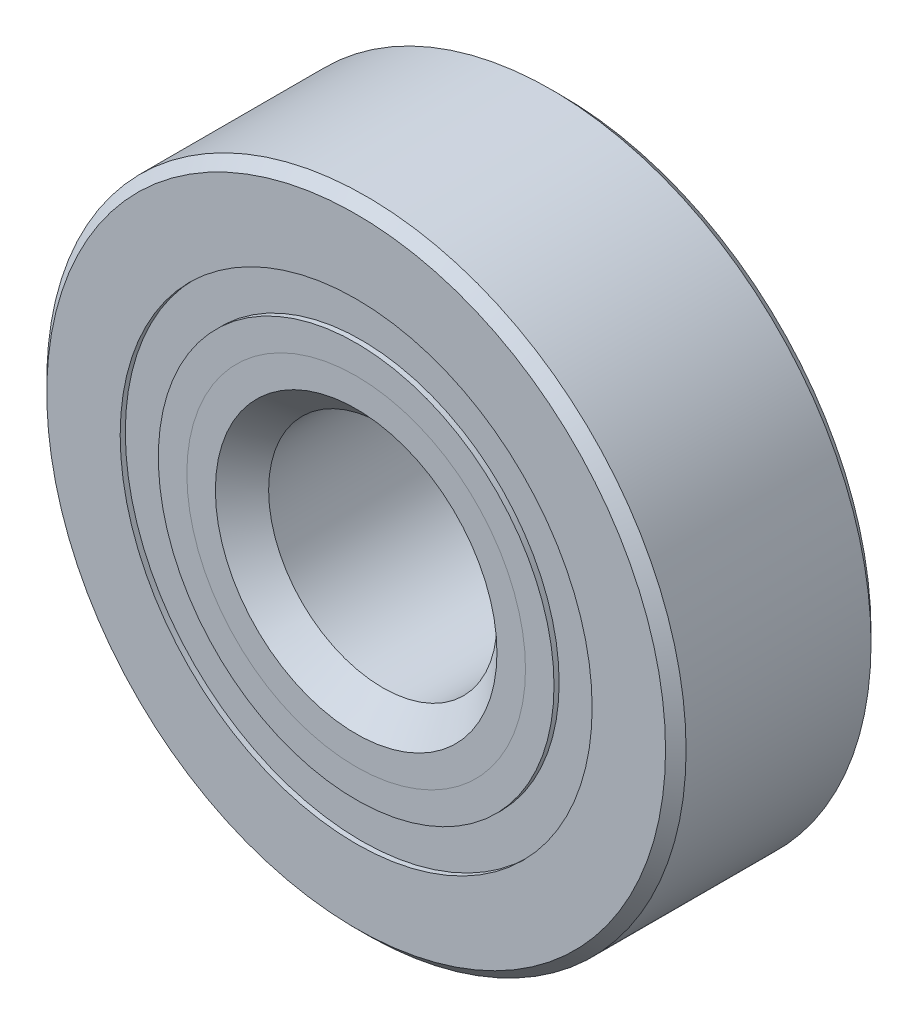
from build123d import *

# Parameters (mm, degrees)
CIRPATTERN1_COUNT = 8
SKETCH5_W         = 1.672929924
SKETCH5_H         = 1.325824176


with BuildPart() as part:
    # Sketch1 → Revolve1 (revolve)
    with BuildSketch(Plane(origin=(0, 0, 0), x_dir=(0, 0, -1), z_dir=(1, 0, 0))):
        with BuildLine():
            Line((3.2146875, 11.1125), (-3.2146875, 11.1125))
            Line((-3.2146875, 11.1125), (-3.571875, 10.7553125))
            Line((-3.571875, 10.7553125), (-3.571875, 8.203537088))
            Line((-3.571875, 8.203537088), (-1.5875, 8.203537088))
            ThreePointArc((-1.5875, 8.203537088), (0, 9.260976326), (1.5875, 8.203537088))
            Line((1.5875, 8.203537088), (3.571875, 8.203537088))
            Line((3.571875, 8.203537088), (3.571875, 10.7553125))
            Line((3.571875, 10.7553125), (3.2146875, 11.1125))
        make_face()
    revolve(axis=Axis((0, 0, 3.571875), (0, 0, -1)))


with BuildPart() as body_2:
    # Sketch2 → Revolve2 (revolve)
    with BuildSketch(Plane(origin=(0, 0, 0), x_dir=(0, 0, -1), z_dir=(1, 0, 0))):
        with BuildLine():
            Line((-3.571875, 6.877712912), (-1.5875, 6.877712912))
            ThreePointArc((-1.5875, 6.877712912), (-0.95372087, 6.108834098), (0, 5.820273674))
            Line((0, 5.820273674), (0, 4.894511837))
            Line((0, 4.894511837), (-2.580274462, 4.894511837))
            Line((-2.580274462, 4.894511837), (-3.571875, 5.886112374))
            Line((-3.571875, 5.886112374), (-3.571875, 6.877712912))
        make_face()
    revolve(axis=Axis((0, 0, 3.571875), (0, 0, -1)))


with BuildPart() as body_3:
    # Sketch3 → Revolve3 (revolve)
    with BuildSketch(Plane(origin=(0, 0, 0), x_dir=(0, 0, -1), z_dir=(1, 0, 0))):
        with BuildLine():
            Line((-3.571875, 5.886112374), (-2.580274462, 4.894511837))
            Line((-2.580274462, 4.894511837), (0, 4.894511837))
            Line((0, 4.894511837), (0, 5.820273674))
            ThreePointArc((0, 5.820273674), (0.95372087, 6.108834098), (1.5875, 6.877712912))
            Line((1.5875, 6.877712912), (3.571875, 6.877712912))
            Line((3.571875, 6.877712912), (3.571875, 4.3259375))
            Line((3.571875, 4.3259375), (3.2146875, 3.96875))
            Line((3.2146875, 3.96875), (-2.646113163, 3.96875))
            Line((-2.646113163, 3.96875), (-3.571875, 4.894511837))
            Line((-3.571875, 4.894511837), (-3.571875, 5.886112374))
        make_face()
    revolve(axis=Axis((0, 0, 3.571875), (0, 0, -1)))


with BuildPart() as body_4:
    # Sketch4 → Revolve4 (revolve)
    with BuildSketch(Plane(origin=(0, 0, 0), x_dir=(0, 0, -1), z_dir=(1, 0, 0))):
        with BuildLine():
            Line((-1.720351326, 7.540625), (1.720351326, 7.540625))
            ThreePointArc((1.720351326, 7.540625), (0, 9.260976326), (-1.720351326, 7.540625))
        make_face()
    revolve(axis=Axis((0, 7.540625, 1.720351326), (0, 0, -1)))


with BuildPart() as cirpattern1_1:
    # CirPattern1: pattern copy
    add(body_4.part.rotate(Axis((0, 0, -3.571875), (0, 0, 1)), 1 * 360 / CIRPATTERN1_COUNT))


with BuildPart() as cirpattern1_2:
    # CirPattern1: pattern copy
    add(body_4.part.rotate(Axis((0, 0, -3.571875), (0, 0, 1)), 2 * 360 / CIRPATTERN1_COUNT))


with BuildPart() as cirpattern1_3:
    # CirPattern1: pattern copy
    add(body_4.part.rotate(Axis((0, 0, -3.571875), (0, 0, 1)), 3 * 360 / CIRPATTERN1_COUNT))


with BuildPart() as cirpattern1_4:
    # CirPattern1: pattern copy
    add(body_4.part.rotate(Axis((0, 0, -3.571875), (0, 0, 1)), 4 * 360 / CIRPATTERN1_COUNT))


with BuildPart() as cirpattern1_5:
    # CirPattern1: pattern copy
    add(body_4.part.rotate(Axis((0, 0, -3.571875), (0, 0, 1)), 5 * 360 / CIRPATTERN1_COUNT))


with BuildPart() as cirpattern1_6:
    # CirPattern1: pattern copy
    add(body_4.part.rotate(Axis((0, 0, -3.571875), (0, 0, 1)), 6 * 360 / CIRPATTERN1_COUNT))


with BuildPart() as cirpattern1_7:
    # CirPattern1: pattern copy
    add(body_4.part.rotate(Axis((0, 0, -3.571875), (0, 0, 1)), 7 * 360 / CIRPATTERN1_COUNT))


with BuildPart() as body_12:
    # Sketch5 → Revolve5 (revolve)
    with BuildSketch(Plane(origin=(0, 0, 0), x_dir=(0, 0, -1), z_dir=(1, 0, 0))):
        with Locations((-2.556816288, 7.540625)):
            Rectangle(SKETCH5_W, SKETCH5_H)
        with Locations((2.556816288, 7.540625)):
            Rectangle(SKETCH5_W, SKETCH5_H)
    revolve(axis=Axis((0, 0, 3.571875), (0, 0, -1)))


solid = Compound([part.part, body_2.part, body_3.part, body_4.part, cirpattern1_1.part, cirpattern1_2.part, cirpattern1_3.part, cirpattern1_4.part, cirpattern1_5.part, cirpattern1_6.part, cirpattern1_7.part, body_12.part])
